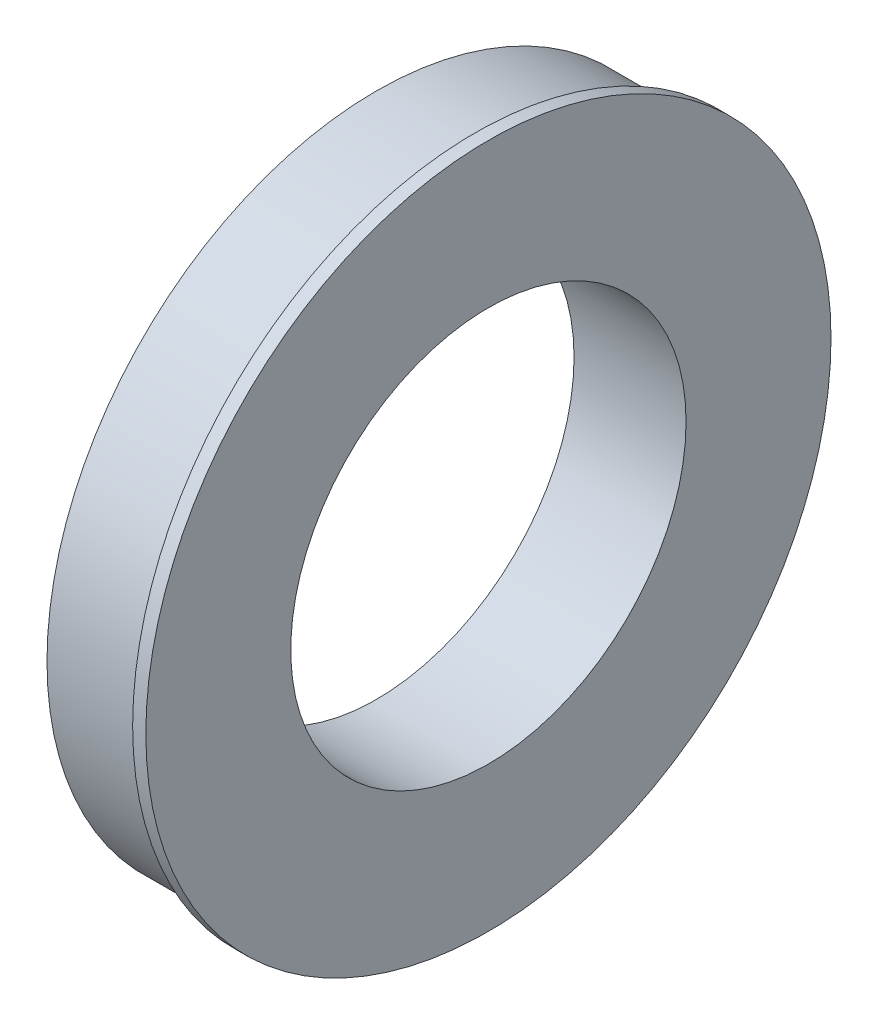
from build123d import *

# Parameters (mm, degrees)
SKETCH1_R           = 63.5
SKETCH1_R_2         = 38.1
BOSS_EXTRUDE1_DEPTH = 9.525
SKETCH2_R           = 66.04
SKETCH2_R_2         = 38.1
BOSS_EXTRUDE2_DEPTH = 2.54


with BuildPart() as part:
    # Sketch1 → Boss-Extrude1 (new body, symmetric)
    with BuildSketch(Plane(origin=(0, 0, 0), x_dir=(0, 0, -1), z_dir=(1, 0, 0))):
        Circle(SKETCH1_R)
        Circle(SKETCH1_R_2, mode=Mode.SUBTRACT)
    extrude(amount=BOSS_EXTRUDE1_DEPTH, both=True)

    # Sketch2 → Boss-Extrude2 (add)
    with BuildSketch(Plane(origin=(9.525, 0, 0), x_dir=(0, 0, -1), z_dir=(1, 0, 0))):
        Circle(SKETCH2_R)
        Circle(SKETCH2_R_2, mode=Mode.SUBTRACT)
    extrude(amount=BOSS_EXTRUDE2_DEPTH)


solid = part.part
